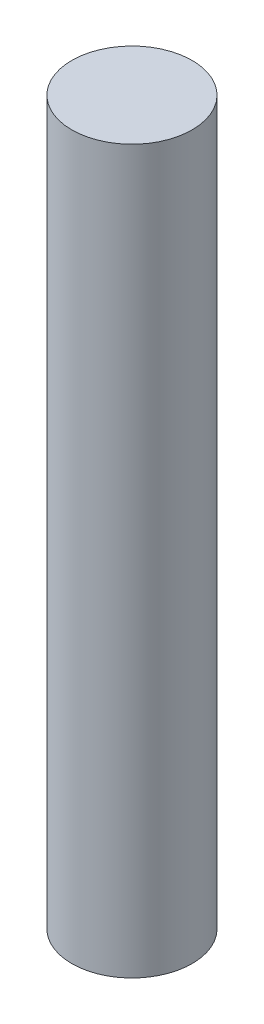
from build123d import *

# Parameters (mm, degrees)
SKETCH_1_R      = 2.5
EXTRUDE_1_DEPTH = 30


with BuildPart() as part:
    # Эскиз1 → Бобышка-Вытянуть1 (new body)
    with BuildSketch(Plane(origin=(0, 0, 0), x_dir=(1, 0, 0), z_dir=(0, 1, 0))):
        Circle(SKETCH_1_R)
    extrude(amount=EXTRUDE_1_DEPTH)


solid = part.part
